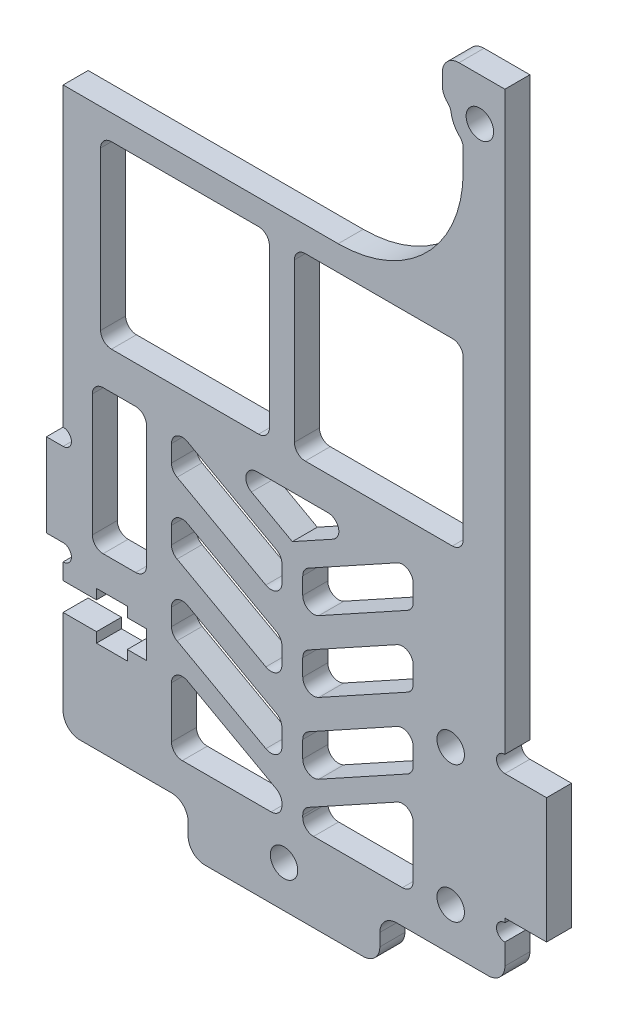
from build123d import *

# Parameters (mm, degrees)
SKETCH_1_W           = 53
SKETCH_1_H           = 150
EXTRUDE_1_DEPTH      = 3
SKETCH_11_R          = 1.65
CUT_EXTRUDE_6_DEPTH  = 10
SKETCH_12_R          = 1.65
CUT_EXTRUDE_7_DEPTH  = 10
SKETCH_13_R          = 1.65
CUT_EXTRUDE_8_DEPTH  = 10
SKETCH_14_W          = 53
SKETCH_14_H          = 15
EXTRUDE_2_DEPTH      = 3
CUT_EXTRUDE_9_DEPTH  = 10
SKETCH_22_W          = 6
SKETCH_22_H          = 35.885928423
CUT_EXTRUDE_10_DEPTH = 10
SKETCH_23_W          = 10
SKETCH_23_H          = 15
EXTRUDE_3_DEPTH      = 3
SKETCH_25_R          = 1.65
CUT_EXTRUDE_12_DEPTH = 10
SKETCH_26_W          = 4
SKETCH_26_H          = 10
EXTRUDE_4_DEPTH      = 3
SKETCH_27_R          = 1
CUT_EXTRUDE_13_DEPTH = 10
SKETCH_28_W          = 3.3
SKETCH_28_H          = 3.3
CUT_EXTRUDE_14_DEPTH = 10
SKETCH_29_W          = 3.7
SKETCH_29_H          = 5.7
CUT_EXTRUDE_15_DEPTH = 10
SKETCH_30_W          = 13.25
SKETCH_30_H          = 22.6
SKETCH_30_W_2        = 20.25
SKETCH_30_H_2        = 21.557035789
SKETCH_30_H_3        = 21.557035788
SKETCH_30_H_4        = 9.4
CUT_EXTRUDE_16_DEPTH = 10
SKETCH_31_W          = 15
SKETCH_31_H          = 5.5
CUT_EXTRUDE_17_DEPTH = 10
SKETCH_32_W          = 6.5
SKETCH_32_H          = 17.25
CUT_EXTRUDE_18_DEPTH = 10
FILLET_1_R           = 1.3
FILLET_2_R           = 2
SKETCH_33_W          = 29.5
SKETCH_33_H          = 35
EXTRUDE_5_DEPTH      = 3
CUT_EXTRUDE_19_DEPTH = 10
SKETCH_35_W          = 2.5
SKETCH_35_H          = 22.689655172
EXTRUDE_6_DEPTH      = 3
FILLET_3_R           = 1.3
SKETCH_37_R          = 1.65
EXTRUDE_7_DEPTH      = 3
FILLET_4_R           = 1.3
SKETCH_38_W          = 6
SKETCH_38_H          = 19.885928423
CUT_EXTRUDE_20_DEPTH = 4
SKETCH_39_W          = 61
SKETCH_39_H          = 26.057035788
CUT_EXTRUDE_21_DEPTH = 4
FILLET_6_R           = 2
FILLET_7_R           = 15
SKETCH_40_R          = 1
CUT_EXTRUDE_22_DEPTH = 4


with BuildPart() as part:
    # 草图1 → 凸台-拉伸1 (new body)
    with BuildSketch(Plane.XY):
        Rectangle(SKETCH_1_W, SKETCH_1_H)
    extrude(amount=EXTRUDE_1_DEPTH)

    # 草图11 → 切除-拉伸6 (cut)
    with BuildSketch(Plane.XY.offset(3)):
        with Locations((0, -70)):
            Circle(SKETCH_11_R)
    extrude(amount=-CUT_EXTRUDE_6_DEPTH, mode=Mode.SUBTRACT)

    # 草图12 → 切除-拉伸7 (cut)
    with BuildSketch(Plane.XY.offset(3)):
        with Locations((-23.5, 54.5)):
            Circle(SKETCH_12_R)
        with Locations((-23.5, 34.5)):
            Circle(SKETCH_12_R)
    extrude(amount=-CUT_EXTRUDE_7_DEPTH, mode=Mode.SUBTRACT)

    # 草图13 → 切除-拉伸8 (cut)
    with BuildSketch(Plane(origin=(0, 0, 0), x_dir=(-1, 0, 0), z_dir=(0, 0, -1))):
        with Locations((-23.5, 18.5)):
            Circle(SKETCH_13_R)
        with Locations((-23.5, 38.5)):
            Circle(SKETCH_13_R)
    extrude(amount=-CUT_EXTRUDE_8_DEPTH, mode=Mode.SUBTRACT)

    # 草图14 → 凸台-拉伸2 (add)
    with BuildSketch(Plane(origin=(0, 0, 0), x_dir=(-1, 0, 0), z_dir=(0, 0, -1))):
        with Locations((0, 82.5)):
            Rectangle(SKETCH_14_W, SKETCH_14_H)
    extrude(amount=-EXTRUDE_2_DEPTH)

    # 草图21 → 切除-拉伸9 (cut)
    with BuildSketch(Plane(origin=(0, 0, 0), x_dir=(-1, 0, 0), z_dir=(0, 0, -1))):
        Polygon((-26.5, 43.5), (-20.5, 43.5), (-20.5, 23.614071577), (20.5, 23.614071577), (20.5, 59.5), (26.5, 59.5), (26.5, 90), (-26.5, 90), align=None)
    extrude(amount=-CUT_EXTRUDE_9_DEPTH, mode=Mode.SUBTRACT)

    # 草图22 → 切除-拉伸10 (cut)
    with BuildSketch(Plane(origin=(0, 0, 0), x_dir=(-1, 0, 0), z_dir=(0, 0, -1))):
        with Locations((23.5, 41.557035789)):
            Rectangle(SKETCH_22_W, SKETCH_22_H)
    extrude(amount=-CUT_EXTRUDE_10_DEPTH, mode=Mode.SUBTRACT)

    # 草图23 → 凸台-拉伸3 (add)
    with BuildSketch(Plane(origin=(0, 0, 0), x_dir=(-1, 0, 0), z_dir=(0, 0, -1))):
        with Locations((-26.5, -55)):
            Rectangle(SKETCH_23_W, SKETCH_23_H)
    extrude(amount=-EXTRUDE_3_DEPTH)

    # 草图25 → 切除-拉伸12 (cut)
    with BuildSketch(Plane(origin=(0, 0, 0), x_dir=(-1, 0, 0), z_dir=(0, 0, -1))):
        with Locations((-20, -48)):
            Circle(SKETCH_25_R)
        with Locations((-20, -64.364049227)):
            Circle(SKETCH_25_R)
    extrude(amount=-CUT_EXTRUDE_12_DEPTH, mode=Mode.SUBTRACT)

    # 草图26 → 凸台-拉伸4 (add)
    with BuildSketch(Plane.XY.offset(3)):
        with Locations((-26.5, -45)):
            Rectangle(SKETCH_26_W, SKETCH_26_H)
    extrude(amount=-EXTRUDE_4_DEPTH)

    # 草图27 → 切除-拉伸13 (cut)
    with BuildSketch(Plane.XY.offset(3)):
        with Locations((-26.5, -39)):
            Circle(SKETCH_27_R)
        with Locations((-26.5, -51)):
            Circle(SKETCH_27_R)
    extrude(amount=-CUT_EXTRUDE_13_DEPTH, mode=Mode.SUBTRACT)

    # 草图28 → 切除-拉伸14 (cut)
    with BuildSketch(Plane.ZY.offset(26.5)):
        with Locations((1.5173157, -55.6)):
            Rectangle(SKETCH_28_W, SKETCH_28_H)
    extrude(amount=-CUT_EXTRUDE_14_DEPTH, mode=Mode.SUBTRACT)

    # 草图29 → 切除-拉伸15 (cut)
    with BuildSketch(Plane(origin=(0, 0, 0), x_dir=(-1, 0, 0), z_dir=(0, 0, -1))):
        with Locations((20.65, -55.6)):
            Rectangle(SKETCH_29_W, SKETCH_29_H)
    extrude(amount=-CUT_EXTRUDE_15_DEPTH, mode=Mode.SUBTRACT)

    # 草图30 → 切除-拉伸16 (cut)
    with BuildSketch(Plane(origin=(0, 0, 0), x_dir=(-1, 0, 0), z_dir=(0, 0, -1))):
        with Locations((6.375, -42.8)):
            Rectangle(SKETCH_30_W, SKETCH_30_H)
        with Locations((-9.875, -42.8)):
            Rectangle(SKETCH_30_W, SKETCH_30_H)
        with Locations((-11.375, -16.221482106)):
            Rectangle(SKETCH_30_W_2, SKETCH_30_H_2)
        with Locations((-11.375, 8.335553683)):
            Rectangle(SKETCH_30_W_2, SKETCH_30_H_3)
        with Locations((11.875, 8.335553683)):
            Rectangle(SKETCH_30_W_2, SKETCH_30_H_3)
        with Locations((11.875, -16.221482106)):
            Rectangle(SKETCH_30_W_2, SKETCH_30_H_2)
        with Locations((-9.875, -61.8)):
            Rectangle(SKETCH_30_W, SKETCH_30_H_4)
        with Locations((6.375, -61.8)):
            Rectangle(SKETCH_30_W, SKETCH_30_H_4)
    extrude(amount=-CUT_EXTRUDE_16_DEPTH, mode=Mode.SUBTRACT)

    # 草图31 → 切除-拉伸17 (cut)
    with BuildSketch(Plane(origin=(0, 0, 0), x_dir=(-1, 0, 0), z_dir=(0, 0, -1))):
        with Locations((-19, -72.25)):
            Rectangle(SKETCH_31_W, SKETCH_31_H)
        with Locations((19, -72.25)):
            Rectangle(SKETCH_31_W, SKETCH_31_H)
    extrude(amount=-CUT_EXTRUDE_17_DEPTH, mode=Mode.SUBTRACT)

    # 草图32 → 切除-拉伸18 (cut)
    with BuildSketch(Plane(origin=(0, 0, 0), x_dir=(-1, 0, 0), z_dir=(0, 0, -1))):
        with Locations((19.75, -40.125)):
            Rectangle(SKETCH_32_W, SKETCH_32_H)
    extrude(amount=-CUT_EXTRUDE_18_DEPTH, mode=Mode.SUBTRACT)

    # 圆角1
    fillet_1_edges = [part.edges().sort_by_distance(p)[0] for p in [
        (3.25, -54.1, 1.5),
        (16.5, -54.1, 1.5),
        (16.5, -31.5, 1.5),
        (3.25, -31.5, 1.5),
        (21.5, -5.442964211, 1.5),
        (1.25, -5.442964211, 1.5),
        (1.25, -27, 1.5),
        (21.5, -27, 1.5),
        (1.25, 19.114071577, 1.5),
        (1.25, -2.442964211, 1.5),
        (-1.75, -2.442964211, 1.5),
        (-1.75, 19.114071577, 1.5),
        (-22, 19.114071577, 1.5),
        (-22, -2.442964211, 1.5),
        (-13, -57.1, 1.5),
        (-13, -66.5, 1.5),
        (0.25, -66.5, 1.5),
        (0.25, -57.1, 1.5),
        (3.25, -57.1, 1.5),
        (3.25, -66.5, 1.5),
        (16.5, -66.5, 1.5),
        (16.5, -57.1, 1.5),
        (-1.75, -5.442964211, 1.5),
        (-22, -5.442964211, 1.5),
        (-22, -27, 1.5),
        (-1.75, -27, 1.5),
        (-13, -54.1, 1.5),
        (0.25, -54.1, 1.5),
        (0.25, -31.5, 1.5),
        (-13, -31.5, 1.5),
        (-16.5, -48.75, 1.5),
        (-16.5, -31.5, 1.5),
        (-23, -31.5, 1.5),
        (-23, -48.75, 1.5),
    ]]
    fillet(fillet_1_edges, radius=FILLET_1_R)

    # 圆角2
    fillet_2_edges = [part.edges().sort_by_distance(p)[0] for p in [
        (-26.5, 23.614071577, 1.5),
        (-11.5, -75, 1.5),
        (11.5, -75, 1.5),
        (26.5, -69.5, 1.5),
        (11.5, -69.5, 1.5),
        (-11.5, -69.5, 1.5),
        (-26.5, -69.5, 1.5),
    ]]
    fillet(fillet_2_edges, radius=FILLET_2_R)

    # 草图33 → 凸台-拉伸5 (add)
    with BuildSketch(Plane(origin=(0, 0, 0), x_dir=(-1, 0, 0), z_dir=(0, 0, -1))):
        with Locations((-1.75, -49)):
            Rectangle(SKETCH_33_W, SKETCH_33_H)
    extrude(amount=-EXTRUDE_5_DEPTH)

    # 草图34 → 切除-拉伸19 (cut)
    with BuildSketch(Plane(origin=(0, 0, 0), x_dir=(-1, 0, 0), z_dir=(0, 0, -1))):
        Polygon((-15.5, -31), (-1, -39), (13.5, -31), (13.5, -36), (-1, -44), (-15.5, -36), align=None)
        Polygon((-15.5, -44.5), (-15.5, -39.5), (-1, -47.5), (13.5, -39.5), (13.5, -44.5), (-1, -52.5), align=None)
        Polygon((-15.5, -53), (-15.5, -48), (-1, -56), (13.5, -48), (13.5, -53), (-1, -61), align=None)
        Polygon((-2.25, -65.5), (-2.25, -63.165602614), (-15.5, -55.855257786), (-15.5, -65.5), align=None)
        Polygon((13.5, -55.855257786), (13.5, -65.5), (0.25, -65.5), (0.25, -63.165602614), align=None)
        Polygon((8.324845262, -31), (-1, -36.144742214), (-10.324845262, -31), align=None)
    extrude(amount=-CUT_EXTRUDE_19_DEPTH, mode=Mode.SUBTRACT)

    # 草图35 → 凸台-拉伸6 (add)
    with BuildSketch(Plane(origin=(0, 0, 0), x_dir=(-1, 0, 0), z_dir=(0, 0, -1))):
        with Locations((-1, -49.655172414)):
            Rectangle(SKETCH_35_W, SKETCH_35_H)
    extrude(amount=-EXTRUDE_6_DEPTH)

    # 圆角3
    fillet_3_edges = [part.edges().sort_by_distance(p)[0] for p in [
        (2.25, -60.310344828, 1.5),
        (-0.25, -60.310344828, 1.5),
        (-0.25, -38.310344828, 1.5),
        (-0.25, -43.310344828, 1.5),
        (-0.25, -46.810344828, 1.5),
        (-0.25, -51.810344828, 1.5),
        (-0.25, -55.310344828, 1.5),
        (2.25, -43.310344828, 1.5),
        (2.25, -46.810344828, 1.5),
        (2.25, -51.810344828, 1.5),
        (2.25, -55.310344828, 1.5),
        (2.25, -38.310344828, 1.5),
        (10.324845262, -31, 1.5),
        (-8.324845262, -31, 1.5),
        (2.25, -65.5, 1.5),
        (15.5, -65.5, 1.5),
        (15.5, -55.855257786, 1.5),
        (2.25, -63.165602614, 1.5),
        (-13.5, -65.5, 1.5),
        (-0.25, -65.5, 1.5),
        (-0.25, -63.165602614, 1.5),
        (-13.5, -55.855257786, 1.5),
        (15.5, -48, 1.5),
        (-13.5, -48, 1.5),
        (-13.5, -53, 1.5),
        (15.5, -53, 1.5),
        (15.5, -39.5, 1.5),
        (-13.5, -39.5, 1.5),
        (-13.5, -44.5, 1.5),
        (15.5, -44.5, 1.5),
        (15.5, -36, 1.5),
        (15.5, -31, 1.5),
        (-13.5, -31, 1.5),
        (-13.5, -36, 1.5),
    ]]
    fillet(fillet_3_edges, radius=FILLET_3_R)

    # 草图37 → 凸台-拉伸7 (add)
    with BuildSketch(Plane(origin=(0, 0, 0), x_dir=(-1, 0, 0), z_dir=(0, 0, -1))):
        with BuildLine():
            ThreePointArc((-26.5, 16.697224362), (-20, 18.5), (-26.5, 20.302775638))
            Line((-26.5, 20.302775638), (-26.5, 16.697224362))
        make_face()
        with Locations((-23.5, 18.5)):
            Circle(SKETCH_37_R, mode=Mode.SUBTRACT)
    extrude(amount=-EXTRUDE_7_DEPTH)

    # 圆角4
    fillet_4_edges = [part.edges().sort_by_distance(p)[0] for p in [
        (20.054290189, 19.114071577, 1.5),
        (21.5, 15.627718677, 1.5),
    ]]
    fillet(fillet_4_edges, radius=FILLET_4_R)

    # 草图38 → 切除-拉伸20 (cut, through all)
    with BuildSketch(Plane(origin=(0, 0, 0), x_dir=(-1, 0, 0), z_dir=(0, 0, -1))):
        with Locations((-23.5, 33.557035789)):
            Rectangle(SKETCH_38_W, SKETCH_38_H)
    extrude(amount=-CUT_EXTRUDE_20_DEPTH, mode=Mode.SUBTRACT)

    # 草图39 → 切除-拉伸21 (cut, through all)
    with BuildSketch(Plane(origin=(0, 0, 0), x_dir=(-1, 0, 0), z_dir=(0, 0, -1))):
        with Locations((11.5, 10.585553683)):
            Rectangle(SKETCH_39_W, SKETCH_39_H)
    extrude(amount=-CUT_EXTRUDE_21_DEPTH, mode=Mode.SUBTRACT)

    # 圆角6
    fillet_6_edges = [part.edges().sort_by_distance(p)[0] for p in [
        (19, 19.089662008, 1.5),
        (19, 23.614071577, 1.5),
    ]]
    fillet(fillet_6_edges, radius=FILLET_6_R)

    # 圆角7
    fillet_7_edges = [part.edges().sort_by_distance(p)[0] for p in [
        (21.5, -2.442964211, 1.5),
    ]]
    fillet(fillet_7_edges, radius=FILLET_7_R)

    # 草图40 → 切除-拉伸22 (cut, through all)
    with BuildSketch(Plane(origin=(0, 0, 0), x_dir=(-1, 0, 0), z_dir=(0, 0, -1))):
        with Locations((-26.5, -46.5)):
            Circle(SKETCH_40_R)
        with Locations((-26.5, -63.996076211)):
            Circle(SKETCH_40_R)
    extrude(amount=-CUT_EXTRUDE_22_DEPTH, mode=Mode.SUBTRACT)


solid = part.part
